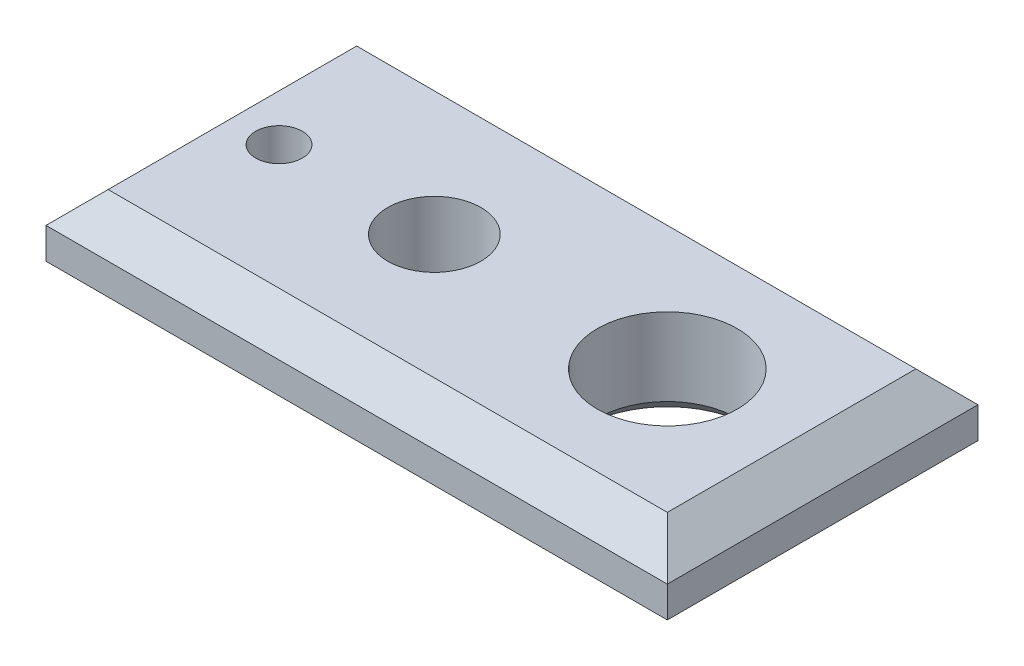
from build123d import *

# Parameters (mm, degrees)
SKETCH1_W           = 200
SKETCH1_H           = 100
SKETCH1_R           = 7.5
SKETCH1_R_2         = 15
SKETCH1_R_3         = 22.5
BOSS_EXTRUDE2_DEPTH = 30
CHAMFER1_SIZE       = 10
CHAMFER4_SIZE       = 5
CHAMFER5_SIZE       = 10


with BuildPart() as part:
    # Sketch1 → Boss-Extrude2 (new body)
    with BuildSketch(Plane(origin=(0, 0, 0), x_dir=(1, 0, 0), z_dir=(0, 1, 0))):
        Rectangle(SKETCH1_W, SKETCH1_H)
        with Locations((-75, 0)):
            Circle(SKETCH1_R, mode=Mode.SUBTRACT)
        with Locations((-25, 0)):
            Circle(SKETCH1_R_2, mode=Mode.SUBTRACT)
        with Locations((50, 0)):
            Circle(SKETCH1_R_3, mode=Mode.SUBTRACT)
    extrude(amount=BOSS_EXTRUDE2_DEPTH)

    # Chamfer1
    chamfer1_edges = [part.edges().sort_by_distance(p)[0] for p in [
        (100, 30, 0),
        (0, 30, -50),
        (-100, 30, 0),
        (0, 30, 50),
    ]]
    chamfer(chamfer1_edges, length=CHAMFER1_SIZE)

    # Chamfer4
    chamfer4_edges = [part.edges().sort_by_distance(p)[0] for p in [
        (-40, 0, 0),
        (-82.5, 0, 0),
        (27.5, 0, 0),
    ]]
    chamfer(chamfer4_edges, length=CHAMFER4_SIZE)

    # Chamfer5
    chamfer5_edges = [part.edges().sort_by_distance(p)[0] for p in [
        (0, 0, -50),
        (100, 0, 0),
        (0, 0, 50),
        (-100, 0, 0),
    ]]
    chamfer(chamfer5_edges, length=CHAMFER5_SIZE)


solid = part.part
